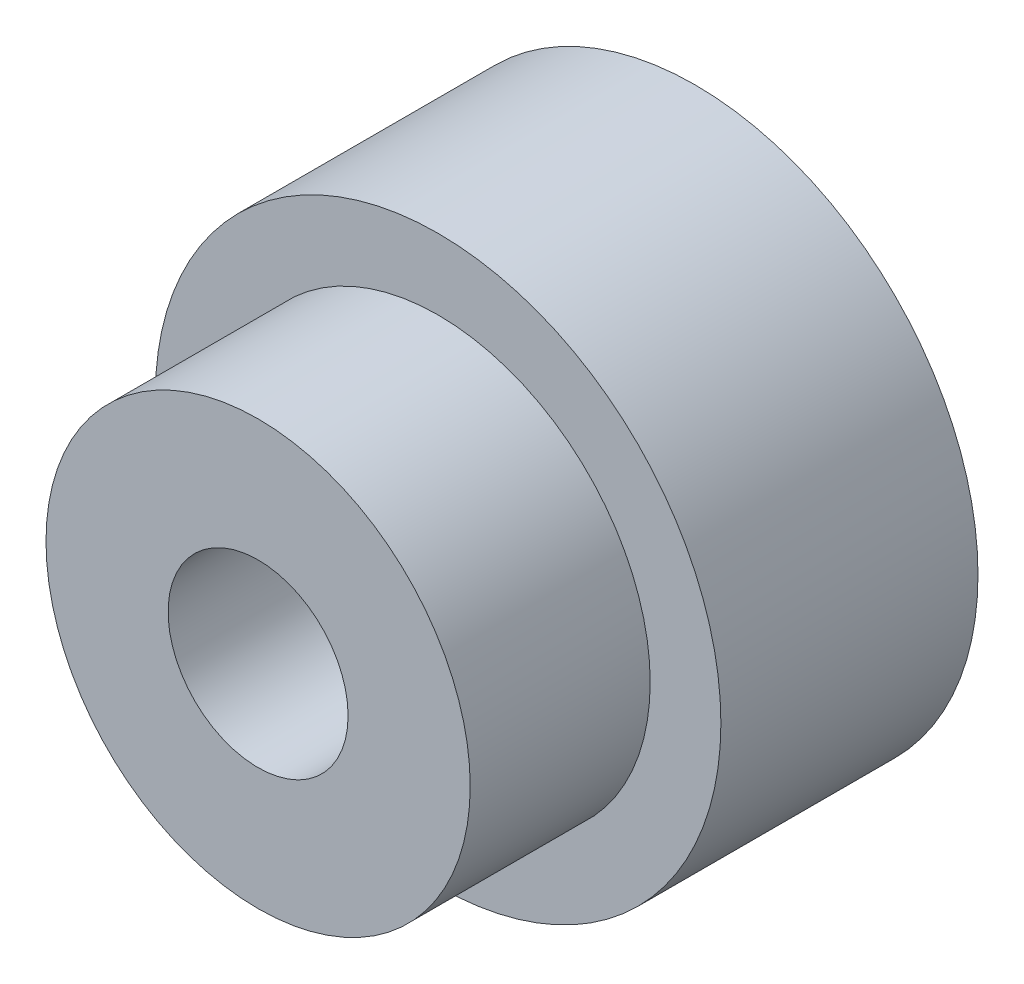
from build123d import *

# Parameters (mm, degrees)
SKETCH_1_R          = 22
EXTRUDE_1_DEPTH     = 20
SKETCH_3_R          = 16.5
EXTRUDE_2_DEPTH     = 14
SKETCH_5_R          = 7
CUT_EXTRUDE_3_DEPTH = 94.8


with BuildPart() as part:
    # 草图1 → 凸台-拉伸1 (new body)
    with BuildSketch(Plane.XY):
        Circle(SKETCH_1_R)
    extrude(amount=EXTRUDE_1_DEPTH)

    # 草图3 → 凸台-拉伸2 (add)
    with BuildSketch(Plane.XY.offset(20)):
        Circle(SKETCH_3_R)
    extrude(amount=EXTRUDE_2_DEPTH)

    # 草图5 → 切除-拉伸3 (cut)
    with BuildSketch(Plane.XY.offset(34)):
        Circle(SKETCH_5_R)
    extrude(amount=-CUT_EXTRUDE_3_DEPTH, mode=Mode.SUBTRACT)


solid = part.part
